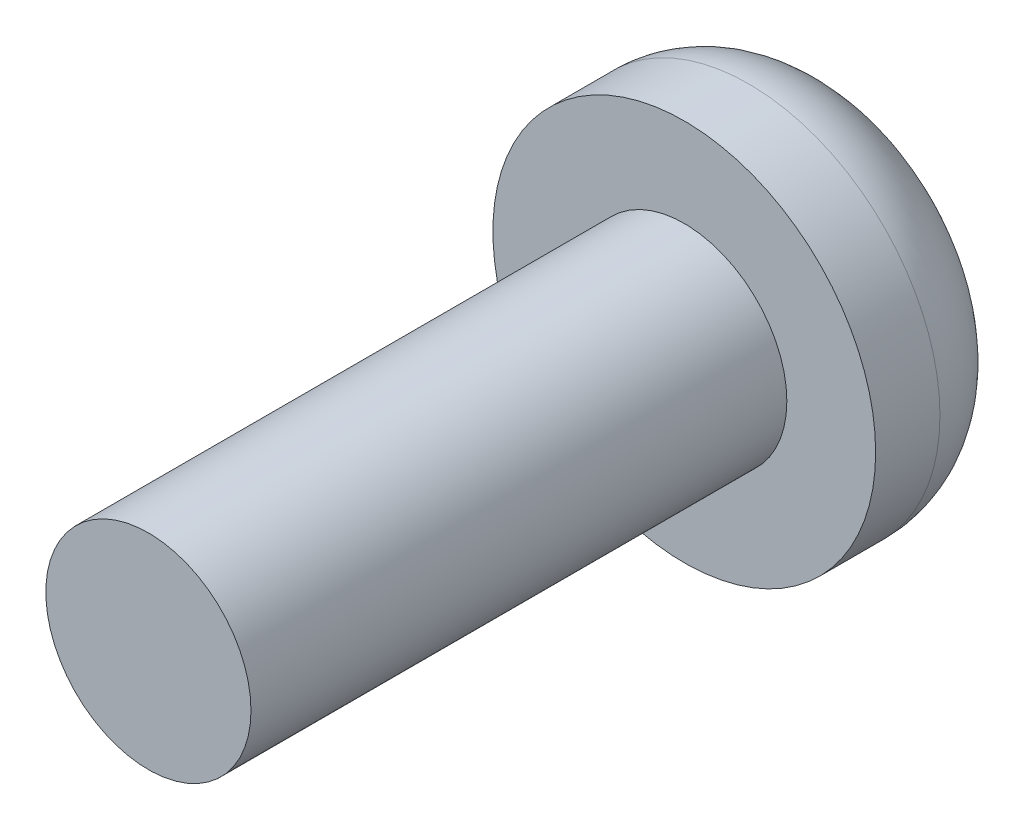
from build123d import *

# Parameters (mm, degrees)
SKETCH1_R         = 3.175
EXTRUDE1_DEPTH    = 2.5908
FILLET1_R         = 1.524
SKETCH2_R         = 1.7018
EXTRUDE2_DEPTH    = 8.89
SKETCH3_W         = 3.27637992
SKETCH3_H         = 0.410534548
EXTRUDE3_DEPTH    = 1.016
CIRPATTERN1_COUNT = 2
CIRPATTERN1_ANGLE = 90


with BuildPart() as part:
    # Sketch1 → Extrude1 (new body)
    with BuildSketch(Plane.XY):
        Circle(SKETCH1_R)
    extrude(amount=EXTRUDE1_DEPTH)

    # Fillet1
    fillet1_edges = [part.edges().sort_by_distance(p)[0] for p in [
        (-3.175, 0, 0),
    ]]
    fillet(fillet1_edges, radius=FILLET1_R)

    # Sketch2 → Extrude2 (add)
    with BuildSketch(Plane.XY.offset(2.5908)):
        Circle(SKETCH2_R)
    extrude(amount=EXTRUDE2_DEPTH)

    # Sketch3 → Extrude3 (cut)
    with BuildSketch(Plane(origin=(0, 0, 0), x_dir=(-1, 0, 0), z_dir=(0, 0, -1))):
        Rectangle(SKETCH3_W, SKETCH3_H)
    extrude3 = extrude(amount=-EXTRUDE3_DEPTH, mode=Mode.SUBTRACT)

    # CirPattern1: Extrude3 ×2 about axis
    cirpattern1_axis = Axis((0, 0, 0), (0, 0, -1))
    for i in range(1, CIRPATTERN1_COUNT):
        add(extrude3.rotate(cirpattern1_axis, i * CIRPATTERN1_ANGLE / (CIRPATTERN1_COUNT - 1)), mode=Mode.SUBTRACT)


solid = part.part
